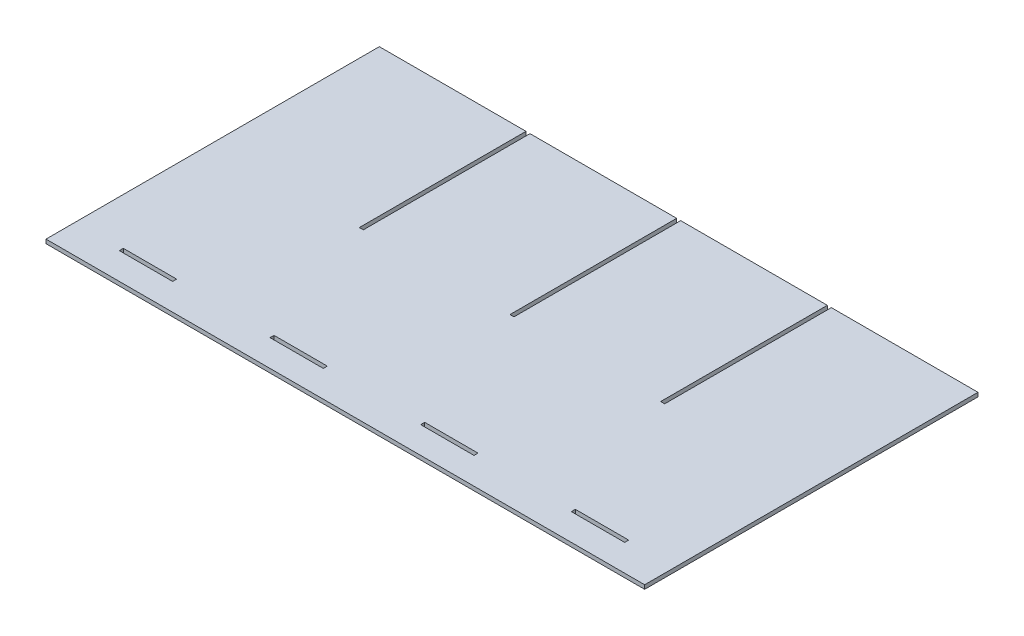
from build123d import *

# Parameters (mm, degrees)
BOSS_EXTRUDE1_DEPTH = 3
SKETCH2_W           = 40
SKETCH2_H           = 3
CUT_EXTRUDE1_DEPTH  = 3


with BuildPart() as part:
    # Sketch1 → Boss-Extrude1 (new body)
    with BuildSketch(Plane(origin=(0, 0, 0), x_dir=(1, 0, 0), z_dir=(0, 1, 0))):
        Polygon((-162.368507953, 89.945054945), (-52.368507953, 89.945054945), (-52.368507953, -35.054945055), (-49.368507953, -35.054945055), (-49.368507953, 89.945054945), (60.631492047, 89.945054945), (60.631492047, -35.054945055), (63.631492047, -35.054945055), (63.631492047, 89.945054945), (173.631492047, 89.945054945), (173.631492047, -35.054945055), (176.631492047, -35.054945055), (176.631492047, 89.945054945), (286.631492047, 89.945054945), (286.631492047, -160.054945055), (-162.368507953, -160.054945055), align=None)
    extrude(amount=BOSS_EXTRUDE1_DEPTH)

    # Sketch2 → Cut-Extrude1 (cut)
    with BuildSketch(Plane(origin=(0, 3, 0), x_dir=(1, 0, 0), z_dir=(0, 1, 0))):
        with Locations((-107.368507953, -138.554945055)):
            Rectangle(SKETCH2_W, SKETCH2_H)
        with Locations((5.631492047, -138.554945055)):
            Rectangle(SKETCH2_W, SKETCH2_H)
        with Locations((118.631492047, -138.554945055)):
            Rectangle(SKETCH2_W, SKETCH2_H)
        with Locations((231.631492047, -138.554945055)):
            Rectangle(SKETCH2_W, SKETCH2_H)
    extrude(amount=-CUT_EXTRUDE1_DEPTH, mode=Mode.SUBTRACT)


solid = part.part
